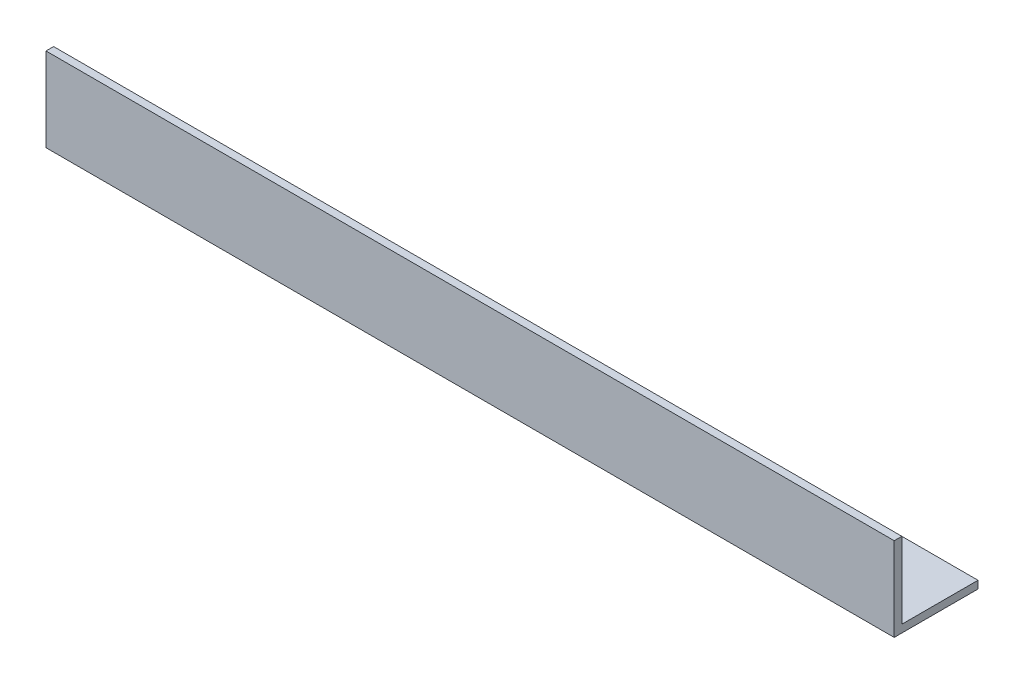
from build123d import *

# Parameters (mm, degrees)
EXTRUDE_1_DEPTH = 334


with BuildPart() as part:
    # Эскиз1 → Вытянуть-Тонкостенный1 (new body)
    with BuildSketch(Plane(origin=(0, 0, 0), x_dir=(0, 0, -1), z_dir=(1, 0, 0))):
        Polygon((0, 33), (0, 0), (33, 0), (33, 3), (3, 3), (3, 33), align=None)
    extrude(amount=EXTRUDE_1_DEPTH)


solid = part.part
